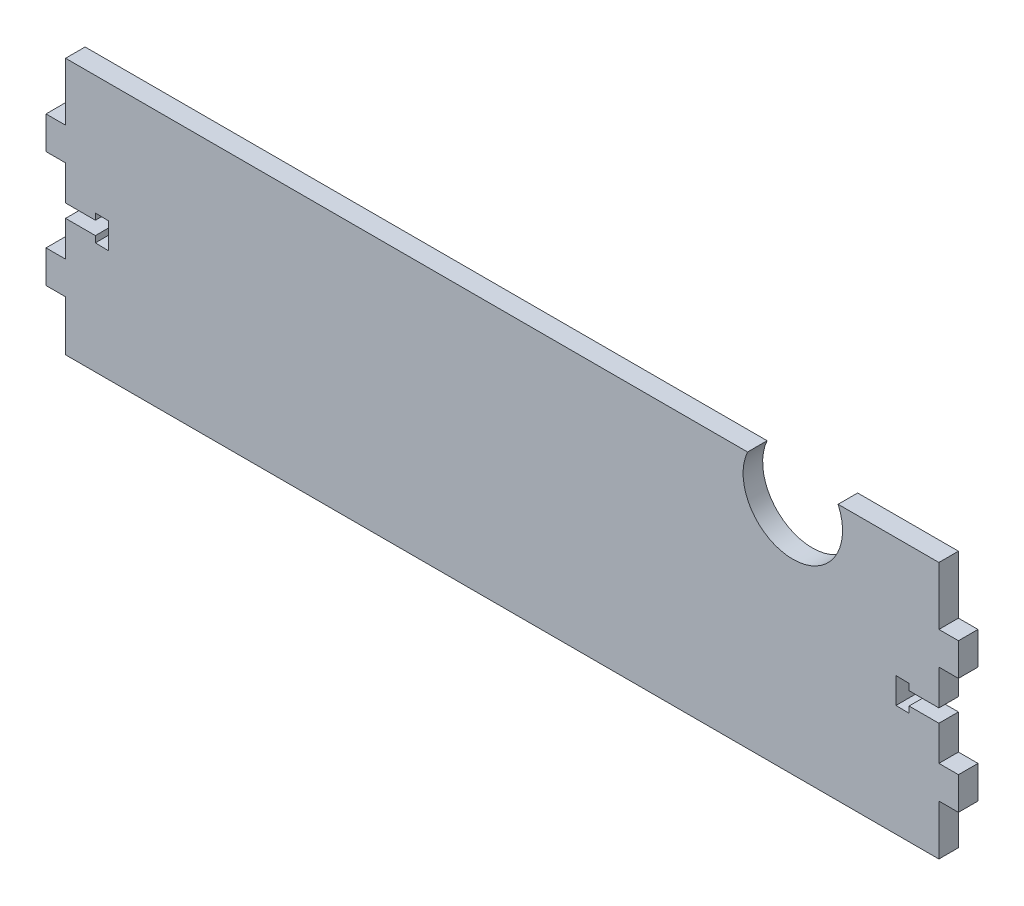
from build123d import *

# Parameters (mm, degrees)
EXTRUDE1_DEPTH = 5.9944


with BuildPart() as part:
    # Sketch1 → Extrude1 (new body)
    with BuildSketch(Plane.XY):
        with BuildLine():
            Line((-209.059629258, -14.077865934), (-209.059629258, -29.477865934))
            Line((-209.059629258, -29.477865934), (58.656370742, -29.477865934))
            Line((58.656370742, -29.477865934), (58.656370742, -14.077865934))
            Line((58.656370742, -14.077865934), (64.650770742, -14.077865934))
            Line((64.650770742, -14.077865934), (64.650770742, -4.077865934))
            Line((64.650770742, -4.077865934), (58.656370742, -4.077865934))
            Line((58.656370742, -4.077865934), (58.656370742, 6.581535434))
            Line((58.656370742, 6.581535434), (49.512370742, 6.581535434))
            Line((49.512370742, 6.581535434), (49.512370742, 4.644785434))
            Line((49.512370742, 4.644785434), (45.512370742, 4.733384066))
            Line((45.512370742, 4.733384066), (45.512370742, 12.670884066))
            Line((45.512370742, 12.670884066), (49.512370742, 12.582285434))
            Line((49.512370742, 12.582285434), (49.512370742, 10.645535434))
            Line((49.512370742, 10.645535434), (58.656370742, 10.645535434))
            Line((58.656370742, 10.645535434), (58.656370742, 21.482134066))
            Line((58.656370742, 21.482134066), (64.650770742, 21.482134066))
            Line((64.650770742, 21.482134066), (64.650770742, 31.482134066))
            Line((64.650770742, 31.482134066), (58.656370742, 31.482134066))
            Line((58.656370742, 31.482134066), (58.656370742, 49.262134066))
            Line((58.656370742, 49.262134066), (27.756302278, 49.262134066))
            ThreePointArc((27.756302278, 49.262134066), (13.878151139, 27.724950493), (0, 49.262134066))
            Line((0, 49.262134066), (-209.059629258, 49.262134066))
            Line((-209.059629258, 49.262134066), (-209.059629258, 31.482134066))
            Line((-209.059629258, 31.482134066), (-215.054029258, 31.482134066))
            Line((-215.054029258, 31.482134066), (-215.054029258, 21.482134066))
            Line((-215.054029258, 21.482134066), (-209.059629258, 21.482134066))
            Line((-209.059629258, 21.482134066), (-209.059629258, 10.822732699))
            Line((-209.059629258, 10.822732699), (-199.915629258, 10.822732699))
            Line((-199.915629258, 10.822732699), (-199.915629258, 12.759482699))
            Line((-199.915629258, 12.759482699), (-195.915629258, 12.670884066))
            Line((-195.915629258, 12.670884066), (-195.915629258, 4.733384066))
            Line((-195.915629258, 4.733384066), (-199.915629258, 4.821982699))
            Line((-199.915629258, 4.821982699), (-199.915629258, 6.758732699))
            Line((-199.915629258, 6.758732699), (-209.059629258, 6.758732699))
            Line((-209.059629258, 6.758732699), (-209.059629258, -4.077865934))
            Line((-209.059629258, -4.077865934), (-215.054029258, -4.077865934))
            Line((-215.054029258, -4.077865934), (-215.054029258, -14.077865934))
            Line((-215.054029258, -14.077865934), (-209.059629258, -14.077865934))
        make_face()
    extrude(amount=EXTRUDE1_DEPTH)


solid = part.part
